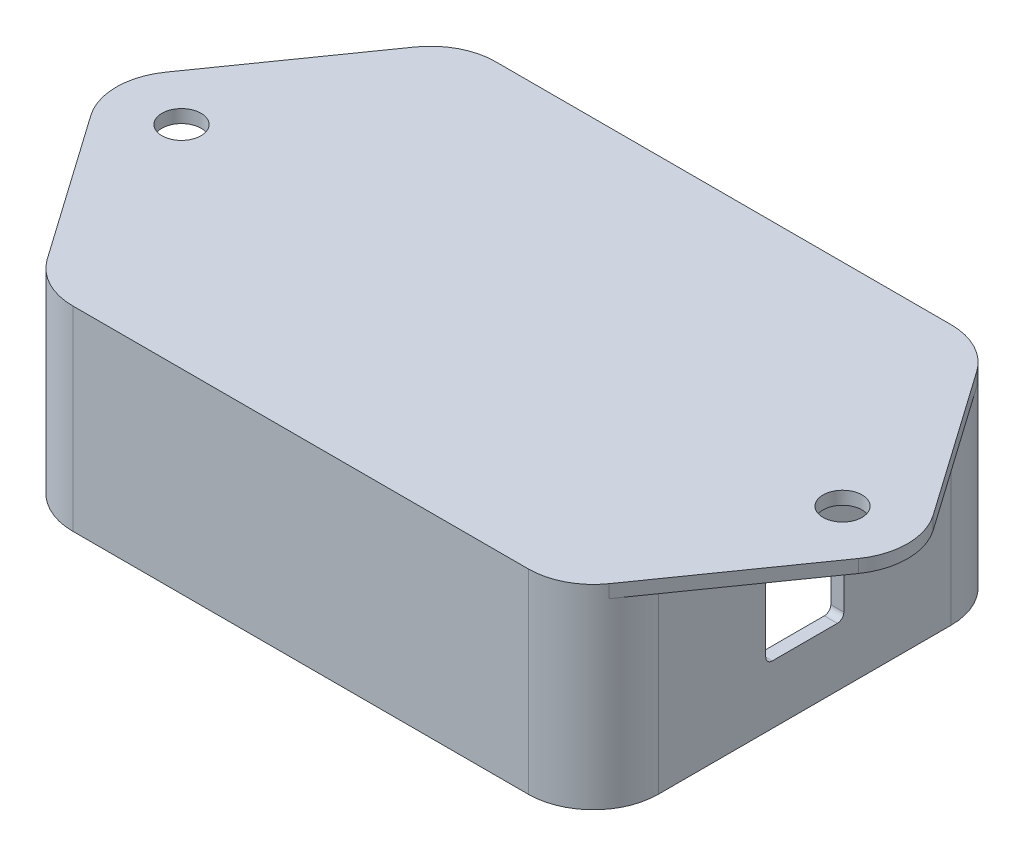
from build123d import *

# Parameters (mm, degrees)
BOSS_EXTRU_1_DEPTH                  = 2
BOSS_EXTRU_2_DEPTH                  = 28
ENL_V_MAT_EXTRU_1_DEPTH             = 28
BOSS_EXTRU_3_DEPTH                  = 22
BOSS_EXTRU_4_DEPTH                  = 6
BOSS_EXTRU_5_DEPTH                  = 22
BOSS_EXTRU_6_DEPTH                  = 6
BOSS_EXTRU_7_DEPTH                  = 22
BOSS_EXTRU_8_DEPTH                  = 6
BOSS_EXTRU_9_DEPTH                  = 22
BOSS_EXTRU_10_DEPTH                 = 6
ENL_V_MAT_EXTRU_2_REACH             = 116.632
ESQUISSE12_W                        = 12
ESQUISSE12_H                        = 12
ESQUISSE13_W                        = 12
ESQUISSE13_H                        = 12
ENL_V_MAT_EXTRU_3_DEPTH             = 115.63237734
D_POUILLE1_ANGLE                    = 1
DIAM_TRE_DU_PER_AGE_6_0_6_1_D       = 6
DIAM_TRE_DU_PER_AGE_6_0_6_1_DEPTH   = 30
DIAM_TRE_DU_PER_AGE_1_8_1_8_1_D     = 1.8
DIAM_TRE_DU_PER_AGE_1_8_1_8_1_DEPTH = 7
PER_AGE1_D                          = 2.65
PER_AGE1_DEPTH                      = 8
CONG_1_R                            = 1
CONG_2_R                            = 10


with BuildPart() as part:
    # Esquisse1 → Boss.-Extru.1 (new body)
    with BuildSketch(Plane.XZ.offset(-7.6)):
        with BuildLine():
            Line((63.019312785, 0), (43.183766285, 28.246822547))
            ThreePointArc((43.183766285, 28.246822547), (39.611495122, 31.373224484), (35, 32.5))
            Line((35, 32.5), (-35, 32.5))
            ThreePointArc((-35, 32.5), (-39.611495122, 31.373224484), (-43.183766285, 28.246822547))
            Line((-43.183766285, 28.246822547), (-63.019312785, 0))
            Line((-63.019312785, 0), (-43.183766285, -28.246822547))
            ThreePointArc((-43.183766285, -28.246822547), (-39.611495122, -31.373224484), (-35, -32.5))
            Line((-35, -32.5), (35, -32.5))
            ThreePointArc((35, -32.5), (39.611495122, -31.373224484), (43.183766285, -28.246822547))
            Line((43.183766285, -28.246822547), (63.019312785, 0))
        make_face()
    extrude(amount=-BOSS_EXTRU_1_DEPTH)

    # Esquisse2 → Boss.-Extru.2 (add)
    with BuildSketch(Plane.XZ.offset(-7.6)):
        with BuildLine():
            Line((-45, -22.5), (-45, 22.5))
            ThreePointArc((-45, 22.5), (-42.071067812, 29.571067812), (-35, 32.5))
            Line((-35, 32.5), (35, 32.5))
            ThreePointArc((35, 32.5), (42.071067812, 29.571067812), (45, 22.5))
            Line((45, 22.5), (45, -22.5))
            ThreePointArc((45, -22.5), (42.071067812, -29.571067812), (35, -32.5))
            Line((35, -32.5), (-35, -32.5))
            ThreePointArc((-35, -32.5), (-42.071067812, -29.571067812), (-45, -22.5))
        make_face()
    extrude(amount=BOSS_EXTRU_2_DEPTH)

    # Esquisse3 → Enlèv. mat.-Extru.1 (cut)
    with BuildSketch(Plane.XZ.offset(20.4)):
        with BuildLine():
            Line((43, -22.5), (43, 22.5))
            ThreePointArc((43, 22.5), (40.656854249, 28.156854249), (35, 30.5))
            Line((35, 30.5), (-35, 30.5))
            ThreePointArc((-35, 30.5), (-40.656854249, 28.156854249), (-43, 22.5))
            Line((-43, 22.5), (-43, -22.5))
            ThreePointArc((-43, -22.5), (-40.656854249, -28.156854249), (-35, -30.5))
            Line((-35, -30.5), (35, -30.5))
            ThreePointArc((35, -30.5), (40.656854249, -28.156854249), (43, -22.5))
        make_face()
    extrude(amount=-ENL_V_MAT_EXTRU_1_DEPTH, mode=Mode.SUBTRACT)

    # Esquisse4 → Boss.-Extru.3 (add)
    with BuildSketch(Plane.XZ.offset(-7.6)):
        with BuildLine():
            Line((42.708099244, -15.5), (43, -15.5))
            Line((43, -15.5), (43, -18.5))
            Line((43, -18.5), (42.708099244, -18.5))
            ThreePointArc((42.708099244, -18.5), (35, -17), (42.708099244, -15.5))
        make_face()
    extrude(amount=BOSS_EXTRU_3_DEPTH)

    # Esquisse5 → Boss.-Extru.4 (add)
    with BuildSketch(Plane.XZ.offset(-7.6)):
        with BuildLine():
            Line((34.492820127, -19.515715167), (35.346896814, -18.629367089))
            ThreePointArc((35.346896814, -18.629367089), (36.224495368, -19.880377412), (37.507179873, -20.710995563))
            Line((37.507179873, -20.710995563), (36.653103186, -21.597343641))
            ThreePointArc((36.653103186, -21.597343641), (30.224495368, -26.107088143), (34.492820127, -19.515715167))
        make_face()
    extrude(amount=BOSS_EXTRU_4_DEPTH)

    # Esquisse6 → Boss.-Extru.5 (add)
    with BuildSketch(Plane.XZ.offset(-7.6)):
        with BuildLine():
            Line((-42.708099244, -18.5), (-43, -18.5))
            Line((-43, -18.5), (-43, -15.5))
            Line((-43, -15.5), (-42.708099244, -15.5))
            ThreePointArc((-42.708099244, -15.5), (-35, -17), (-42.708099244, -18.5))
        make_face()
    extrude(amount=BOSS_EXTRU_5_DEPTH)

    # Esquisse7 → Boss.-Extru.6 (add)
    with BuildSketch(Plane.XZ.offset(-7.6)):
        with BuildLine():
            Line((-36.682682292, -21.438638051), (-37.438638051, -20.682682292))
            ThreePointArc((-37.438638051, -20.682682292), (-36.171572875, -19.828427125), (-35.317317708, -18.561361949))
            Line((-35.317317708, -18.561361949), (-34.561361949, -19.317317708))
            ThreePointArc((-34.561361949, -19.317317708), (-30.171572875, -25.828427125), (-36.682682292, -21.438638051))
        make_face()
    extrude(amount=BOSS_EXTRU_6_DEPTH)

    # Esquisse8 → Boss.-Extru.7 (add)
    with BuildSketch(Plane.XZ.offset(-7.6)):
        with BuildLine():
            Line((42.708099244, 18.5), (43, 18.5))
            Line((43, 18.5), (43, 15.5))
            Line((43, 15.5), (42.708099244, 15.5))
            ThreePointArc((42.708099244, 15.5), (35, 17), (42.708099244, 18.5))
        make_face()
    extrude(amount=BOSS_EXTRU_7_DEPTH)

    # Esquisse9 → Boss.-Extru.8 (add)
    with BuildSketch(Plane.XZ.offset(-7.6)):
        with BuildLine():
            Line((36.682682292, 21.438638051), (37.438638051, 20.682682292))
            ThreePointArc((37.438638051, 20.682682292), (36.171572875, 19.828427125), (35.317317708, 18.561361949))
            Line((35.317317708, 18.561361949), (34.561361949, 19.317317708))
            ThreePointArc((34.561361949, 19.317317708), (30.171572875, 25.828427125), (36.682682292, 21.438638051))
        make_face()
    extrude(amount=BOSS_EXTRU_8_DEPTH)

    # Esquisse10 → Boss.-Extru.9 (add)
    with BuildSketch(Plane.XZ.offset(-7.6)):
        with BuildLine():
            Line((-42.708099244, 15.5), (-43, 15.5))
            Line((-43, 15.5), (-43, 18.5))
            Line((-43, 18.5), (-42.708099244, 18.5))
            ThreePointArc((-42.708099244, 18.5), (-35, 17), (-42.708099244, 15.5))
        make_face()
    extrude(amount=BOSS_EXTRU_9_DEPTH)

    # Esquisse11 → Boss.-Extru.10 (add)
    with BuildSketch(Plane.XZ.offset(-7.6)):
        with BuildLine():
            Line((-34.561361949, 19.317317708), (-35.317317708, 18.561361949))
            ThreePointArc((-35.317317708, 18.561361949), (-36.171572875, 19.828427125), (-37.438638051, 20.682682292))
            Line((-37.438638051, 20.682682292), (-36.682682292, 21.438638051))
            ThreePointArc((-36.682682292, 21.438638051), (-30.171572875, 25.828427125), (-34.561361949, 19.317317708))
        make_face()
    extrude(amount=BOSS_EXTRU_10_DEPTH)

    # Esquisse12 → Enlèv. mat.-Extru.2 (cut, up to next)
    with BuildSketch(Plane.ZY.offset(45), mode=Mode.PRIVATE) as enl_v_mat_extru_2_sk1:
        with Locations((0, -5.4)):
            Rectangle(ESQUISSE12_W, ESQUISSE12_H)
    enl_v_mat_extru_2_tool1 = extrude(enl_v_mat_extru_2_sk1.sketch, amount=-ENL_V_MAT_EXTRU_2_REACH, mode=Mode.PRIVATE) & part.part
    add(enl_v_mat_extru_2_tool1.solids().sort_by_distance((-45, -5.4, 0))[0], mode=Mode.SUBTRACT)

    # Esquisse13 → Enlèv. mat.-Extru.3 (cut, through all)
    with BuildSketch(Plane(origin=(45, 0, 0), x_dir=(0, 0, -1), z_dir=(1, 0, 0))):
        with Locations((0, -5.4)):
            Rectangle(ESQUISSE13_W, ESQUISSE13_H)
    extrude(amount=-ENL_V_MAT_EXTRU_3_DEPTH, mode=Mode.SUBTRACT)

    # Dépouille1
    d_pouille1_faces = [part.faces().sort_by_distance(p)[0] for p in [
        (-35, -3.4, 17),
        (35, -3.4, 17),
        (35, -3.4, -17),
        (-35, -3.4, -17),
    ]]
    draft(d_pouille1_faces, Plane(origin=(35, 7.6, -22.5), x_dir=(0, 0, -1), z_dir=(0, -1, 0)), D_POUILLE1_ANGLE)

    # Diamètre du perçage Ø6.0 (6)1
    with Locations(Plane(origin=(0, 9.6, 0), x_dir=(1, 0, 0), z_dir=(0, 1, 0))):
        with Locations((-50.8, 0), (50.8, 0)):
            Hole(DIAM_TRE_DU_PER_AGE_6_0_6_1_D / 2, depth=DIAM_TRE_DU_PER_AGE_6_0_6_1_DEPTH)

    # Diamètre du perçage Ø1.8 (1.8)1
    with Locations(Plane(origin=(0, 1.6, 0), x_dir=(-1, 0, 0), z_dir=(0, -1, 0))):
        with Locations((33, -23), (-33, -23), (-33, 23.22671073), (33, 23)):
            Hole(DIAM_TRE_DU_PER_AGE_1_8_1_8_1_D / 2, depth=DIAM_TRE_DU_PER_AGE_1_8_1_8_1_DEPTH)

    # Perçage1
    with Locations(Plane(origin=(0, -14.4, 0), x_dir=(-1, 0, 0), z_dir=(0, -1, 0))):
        with Locations((-39, 17), (-39, -17), (39, 17), (39, -17)):
            Hole(PER_AGE1_D / 2, depth=PER_AGE1_DEPTH)

    # Congé1
    cong_1_edges = [part.edges().sort_by_distance(p)[0] for p in [
        (-44, -11.4, -6),
        (-44, 0.6, -6),
        (-44, 0.6, 6),
        (-44, -11.4, 6),
        (44, -11.4, -6),
        (44, 0.6, 6),
        (44, 0.6, -6),
        (44, -11.4, 6),
    ]]
    fillet(cong_1_edges, radius=CONG_1_R)

    # Congé2
    cong_2_edges = [part.edges().sort_by_distance(p)[0] for p in [
        (-63.019312785, 8.6, 0),
        (63.019312785, 8.6, 0),
    ]]
    fillet(cong_2_edges, radius=CONG_2_R)


solid = part.part
